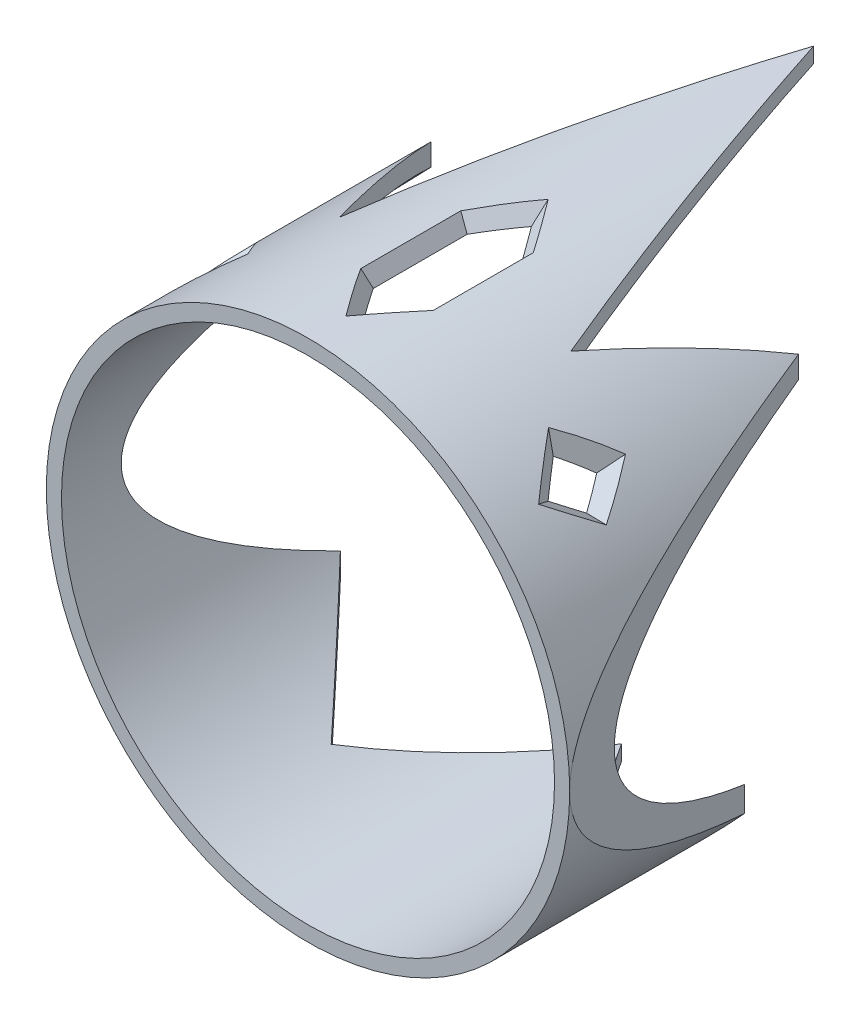
from build123d import *

# Parameters (mm, degrees)
CROQUIS1_R               = 103.5
CROQUIS1_R_2             = 97.5
BASE_DEPTH               = 200
DISE_O_DEPTH             = 150
DISE_O_DEPTH_BACK        = 150
PATR_NTRASERO_DEPTH      = 20
PATR_NTRASERO_DEPTH_BACK = 90


with BuildPart() as part:
    # Croquis1 → Base (new body)
    with BuildSketch(Plane.XY):
        Circle(CROQUIS1_R)
        Circle(CROQUIS1_R_2, mode=Mode.SUBTRACT)
    extrude(amount=BASE_DEPTH)

    # Croquis2 → Diseño (cut, two sides: drawn at the far end of the back side and taken through both)
    with BuildSketch(Plane(origin=(0, 0, 0), x_dir=(1, 0, 0), z_dir=(0, 1, 0)).offset(-DISE_O_DEPTH_BACK)):
        Polygon((-103.5, 0), (-103.5, -200), (-72.714481971, -78.691726895), (-45.812787176, -141.817485969), (0, 0), align=None)
        Polygon((72.714481971, -78.691726895), (103.5, -200), (103.5, 0), (0, 0), (45.812787176, -141.817485969), align=None)
    extrude(amount=DISE_O_DEPTH + DISE_O_DEPTH_BACK, mode=Mode.SUBTRACT)

    # Croquis12 → PatrónTrasero (cut, two sides: drawn at the far end of the back side and taken through both)
    with BuildSketch(Plane(origin=(0, -90, 0), x_dir=(-1, 0, 0), z_dir=(0, -1, 0)).offset(-PATR_NTRASERO_DEPTH_BACK)):
        Polygon((-103.5, 1.909548239), (-103.5, -200), (-79.959810945, -107.241460736), (-45.812787176, -145.013726935), (0, -76.028192757), (45.812787176, -145.013726935), (79.959810945, -107.241460736), (103.5, -200), (103.5, 1.909548239), align=None)
    extrude(amount=PATR_NTRASERO_DEPTH + PATR_NTRASERO_DEPTH_BACK, mode=Mode.SUBTRACT)

    # Croquis14 → RanuraPrimalJewel section 0
    with BuildSketch(Plane(origin=(0, 103.5, 0), x_dir=(1, 0, 0), z_dir=(0, 1, 0))):
        with BuildLine():
            Line((15, -165), (15, -125))
            Line((15, -125), (0, -105))
            Line((0, -105), (-15, -125))
            Line((-15, -125), (-15, -165))
            Line((-15, -165), (0, -185))
            Line((0, -185), (15, -165))
        make_face()
    # Croquis17 → RanuraPrimalJewel section 1
    with BuildSketch(Plane(origin=(0, 94.5, 0), x_dir=(1, 0, 0), z_dir=(0, 1, 0))):
        with BuildLine():
            Line((-9, -127), (0, -115))
            Line((0, -115), (9, -127))
            Line((9, -127), (9, -163))
            Line((9, -163), (0, -175))
            Line((0, -175), (-9, -163))
            Line((-9, -163), (-9, -127))
        make_face()
    loft(mode=Mode.SUBTRACT)

    # Croquis20 → Cortar-Recubrir1 section 0
    with BuildSketch(Plane(origin=(-65.973382939, 79.748120627, 0), x_dir=(0, 0, 1), z_dir=(-0.6374239897486909, 0.7705132427757883, 0))):
        with BuildLine():
            Line((146.644660941, -9.078894023), (164.32233047, -26.756563553))
            Line((164.32233047, -26.756563553), (182, -9.078894023))
            Line((182, -9.078894023), (164.32233047, 8.598775507))
            Line((164.32233047, 8.598775507), (146.644660941, -9.078894023))
        make_face()
    # Croquis22 → Cortar-Recubrir1 section 1
    with BuildSketch(Plane(origin=(-60.236567031, 72.813501442, 0), x_dir=(0, 0, 1), z_dir=(-0.6374239897486909, 0.7705132427757883, 0))):
        with BuildLine():
            Line((157.95836944, -9.078894023), (164.32233047, -15.442855054))
            Line((164.32233047, -15.442855054), (170.686291501, -9.078894023))
            Line((170.686291501, -9.078894023), (164.32233047, -2.714932992))
            Line((164.32233047, -2.714932992), (157.95836944, -9.078894023))
        make_face()
    loft(mode=Mode.SUBTRACT)

    # Croquis30 → Cortar-Recubrir2 section 0
    with BuildSketch(Plane(origin=(60.236567031, 72.813501442, 0), x_dir=(0, 0, 1), z_dir=(0.6374239897486909, 0.7705132427757883, 0))):
        with BuildLine():
            Line((157.95836944, 9.078894023), (164.32233047, 2.714932992))
            Line((164.32233047, 2.714932992), (170.686291501, 9.078894023))
            Line((170.686291501, 9.078894023), (164.32233047, 15.442855054))
            Line((164.32233047, 15.442855054), (157.95836944, 9.078894023))
        make_face()
    # Croquis29 → Cortar-Recubrir2 section 1
    with BuildSketch(Plane(origin=(65.973382939, 79.748120627, 0), x_dir=(0, 0, 1), z_dir=(0.6374239897486909, 0.7705132427757883, 0))):
        with BuildLine():
            Line((182, 9.078894023), (164.32233047, 26.756563553))
            Line((164.32233047, 26.756563553), (146.644660941, 9.078894023))
            Line((146.644660941, 9.078894023), (164.32233047, -8.598775507))
            Line((164.32233047, -8.598775507), (182, 9.078894023))
        make_face()
    loft(mode=Mode.SUBTRACT)


solid = part.part
